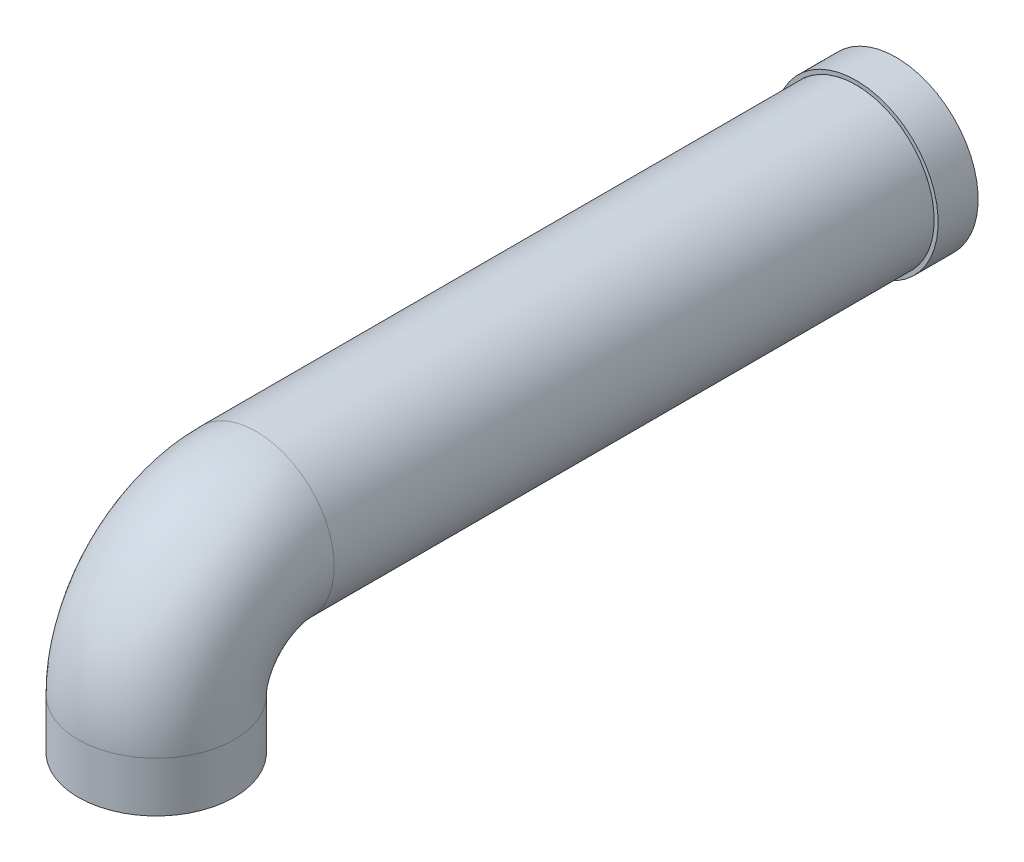
from build123d import *

# Parameters (mm, degrees)
SWEEP2_PROFILE_R    = 39
SKETCH8_R           = 41
SKETCH8_R_2         = 39
BOSS_EXTRUDE1_DEPTH = 20
SKETCH11_R          = 25
CUT_EXTRUDE1_DEPTH  = 300


with BuildPart() as part:
    # Sweep2: sweep along a path in Sketch2
    with BuildLine(Plane(origin=(0, 0, 0), x_dir=(0, 0, -1), z_dir=(1, 0, 0))) as sweep2_path:
        Line((0, 0), (0, 25))
        ThreePointArc((0, 25), (14.644660941, 60.355339059), (50, 75))
        Line((50, 75), (350, 75))
    # Sweep2 profile (on start of the path) → Sweep2 (sweep)
    with BuildSketch(Plane.ZX):
        Circle(SWEEP2_PROFILE_R)
    sweep(path=sweep2_path.line)

    # Sketch11 → Cut-Extrude1 (cut)
    with BuildSketch(Plane(origin=(0, 0, -350), x_dir=(-1, 0, 0), z_dir=(0, 0, -1))):
        with Locations((0, 75)):
            Circle(SKETCH11_R)
    extrude(amount=-CUT_EXTRUDE1_DEPTH, mode=Mode.SUBTRACT)


with BuildPart() as body_2:
    # Sketch8 → Boss-Extrude1 (new body)
    with BuildSketch(Plane(origin=(0, 0, -350), x_dir=(-1, 0, 0), z_dir=(0, 0, -1))):
        with Locations((0, 75)):
            Circle(SKETCH8_R)
        with Locations((0, 75)):
            Circle(SKETCH8_R_2, mode=Mode.SUBTRACT)
    extrude(amount=BOSS_EXTRUDE1_DEPTH)


solid = Compound([part.part, body_2.part])
